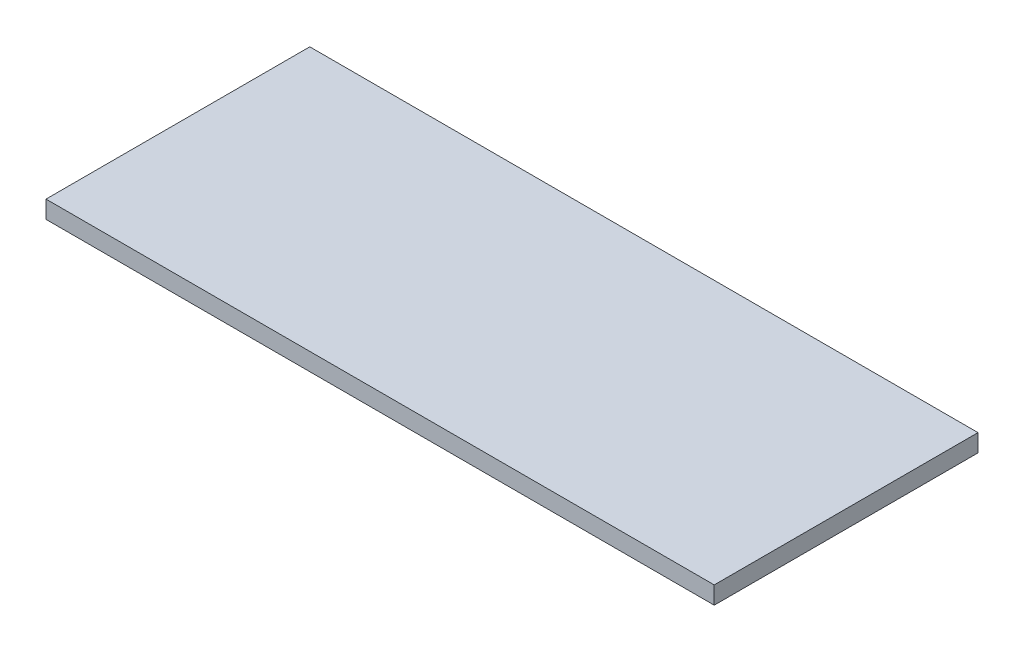
from build123d import *

# Parameters (mm, degrees)
SKETCH1_W           = 304
SKETCH1_H           = 120
BOSS_EXTRUDE1_DEPTH = 8


with BuildPart() as part:
    # Sketch1 → Boss-Extrude1 (new body)
    with BuildSketch(Plane(origin=(0, 0, 0), x_dir=(1, 0, 0), z_dir=(0, 1, 0))):
        with Locations((152, 60)):
            Rectangle(SKETCH1_W, SKETCH1_H)
    extrude(amount=BOSS_EXTRUDE1_DEPTH)


solid = part.part
